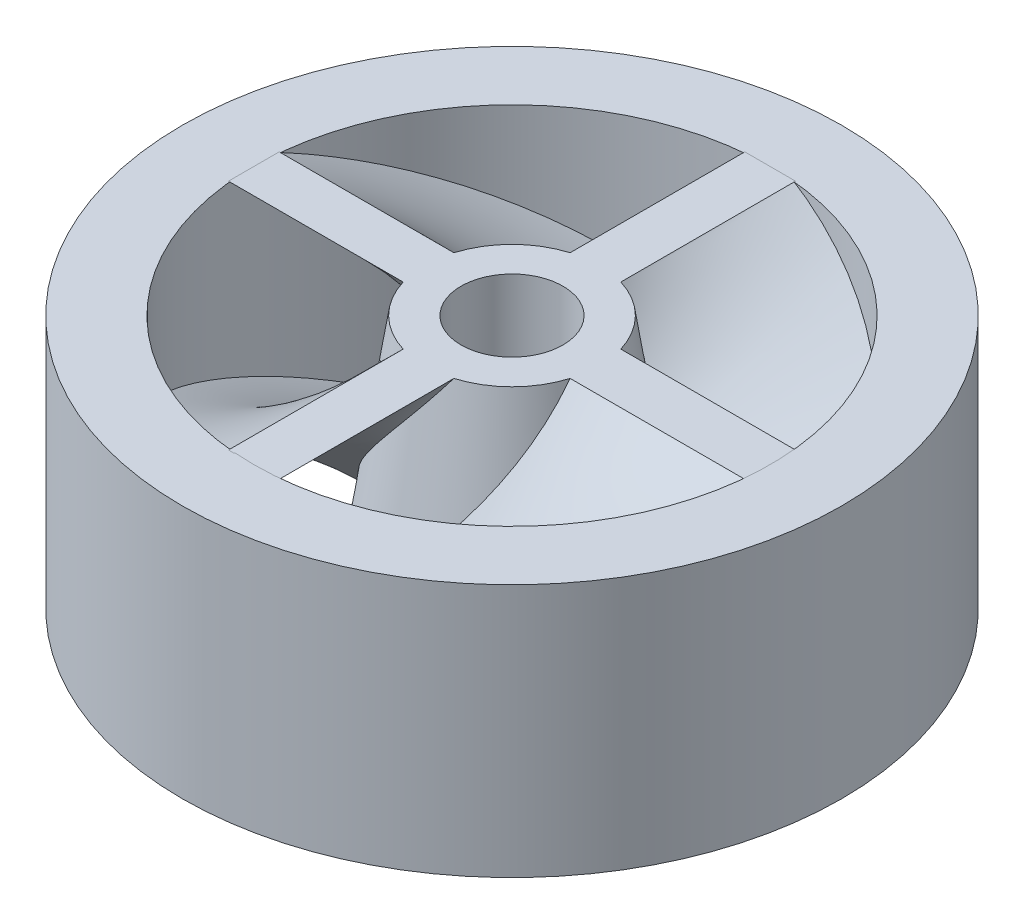
from build123d import *

# Parameters (mm, degrees)
SWEEP1_PITCH           = 38.862
SWEEP1_HEIGHT          = 12.7
SWEEP1_RADIUS          = 12.9286
SWEEP1_START_ANGLE     = 180
SKETCH2_W              = 2.54
SKETCH2_H              = 12.9286
CIRPATTERN1_COUNT      = 4
F_10_CLEARANCE_HOLE1_D = 5.1054
SKETCH11_W             = 3.5814
SKETCH11_H             = 12.7


with BuildPart() as part:
    # Sweep1: sweep along a helix
    with BuildLine() as sweep1_path:
        add(Helix(SWEEP1_PITCH, SWEEP1_HEIGHT, SWEEP1_RADIUS, center=(0, 0, 0), direction=(0, -1, 0), mode=Mode.PRIVATE).rotate(Axis((0, 0, 0), (0, -1, 0)), SWEEP1_START_ANGLE))
    # Sketch2 → Sweep1 (sweep)
    with BuildSketch(Plane(origin=(0, 0, 0), x_dir=(1, 0, 0), z_dir=(0, 1, 0))):
        with Locations((0, -6.4643)):
            Rectangle(SKETCH2_W, SKETCH2_H)
    sweep1 = sweep(path=sweep1_path.line, is_frenet=True)

    # Sketch4 → Revolve1 (revolve)
    with BuildSketch(Plane.XY):
        Polygon((0, 0), (0, -12.700196986), (6.35, -12.700196986), (4.3688, 0), align=None)
    revolve(axis=Axis((0, 0, 0), (0, -1, 0)))

    # CirPattern1: Sweep1 ×4 about axis
    cirpattern1_axis = Axis((0, 28.922533895, 0), (0, -1, 0))
    for i in range(1, CIRPATTERN1_COUNT):
        add(sweep1.rotate(cirpattern1_axis, i * 360 / CIRPATTERN1_COUNT))

    # #10 Clearance Hole1 (through all)
    with Locations(Plane.ZX):
        with Locations((0, 0)):
            Hole(F_10_CLEARANCE_HOLE1_D / 2)


with BuildPart() as body_2:
    # Sketch11 → Revolve2 (revolve)
    with BuildSketch(Plane.XY):
        with Locations((14.7193, -6.35)):
            Rectangle(SKETCH11_W, SKETCH11_H)
    revolve(axis=Axis((0, 28.922533895, 0), (0, -1, 0)))


solid = Compound([part.part, body_2.part])
